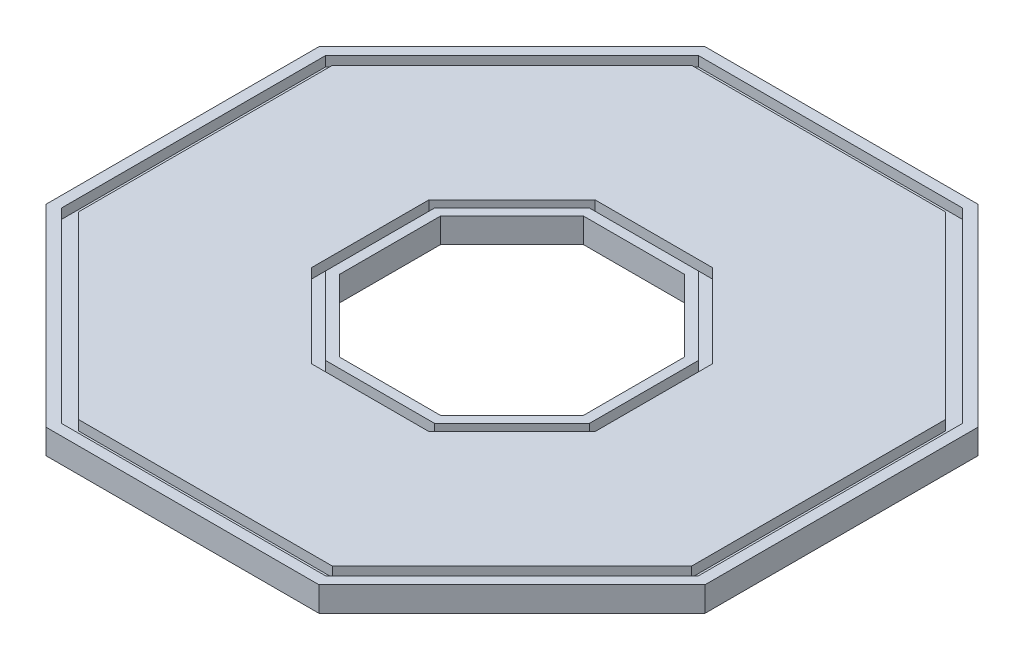
from build123d import *

# Parameters (mm, degrees)
EXTRUDE_1_DEPTH     = 2.5
CUT_EXTRUDE_1_DEPTH = 1
CUT_EXTRUDE_2_DEPTH = 3.8
CUT_EXTRUDE_3_DEPTH = 1


with BuildPart() as part:
    # 스케치1 → 보스-돌출1 (new body)
    with BuildSketch(Plane(origin=(0, 0, 0), x_dir=(1, 0, 0), z_dir=(0, 1, 0))):
        Polygon((-13.776603565, -33.25966317), (13.776603565, -33.25966317), (33.25966317, -13.776603565), (33.25966317, 13.776603565), (13.776603565, 33.25966317), (-13.776603565, 33.25966317), (-33.25966317, 13.776603565), (-33.25966317, -13.776603565), align=None)
    extrude(amount=EXTRUDE_1_DEPTH)

    # 스케치2 → 컷-돌출1 (cut)
    with BuildSketch(Plane(origin=(0, 2.5, 0), x_dir=(1, 0, 0), z_dir=(0, 1, 0))):
        Polygon((13.317383446, -32.151007731), (32.151007731, -13.317383446), (32.151007731, 13.317383446), (13.317383446, 32.151007731), (-13.317383446, 32.151007731), (-32.151007731, 13.317383446), (-32.151007731, -13.317383446), (-13.317383446, -32.151007731), align=None)
        Polygon((12.820327171, -30.951007731), (30.951007731, -12.820327171), (30.951007731, 12.820327171), (12.820327171, 30.951007731), (-12.820327171, 30.951007731), (-30.951007731, 12.820327171), (-30.951007731, -12.820327171), (-12.820327171, -30.951007731), align=None, mode=Mode.SUBTRACT)
    extrude(amount=-CUT_EXTRUDE_1_DEPTH, mode=Mode.SUBTRACT)

    # 스케치4 → 컷-돌출2 (cut)
    with BuildSketch(Plane(origin=(0, 2.5, 0), x_dir=(1, 0, 0), z_dir=(0, 1, 0))):
        Polygon((-5.103166077, -12.320132754), (5.103166077, -12.320132754), (12.320132754, -5.103166077), (12.320132754, 5.103166077), (5.103166077, 12.320132754), (-5.103166077, 12.320132754), (-12.320132754, 5.103166077), (-12.320132754, -5.103166077), align=None)
    extrude(amount=-CUT_EXTRUDE_2_DEPTH, mode=Mode.SUBTRACT)

    # 스케치4<3> → 컷-돌출3 (cut)
    with BuildSketch(Plane(origin=(0, 2.5, 0), x_dir=(1, 0, 0), z_dir=(0, 1, 0))):
        Polygon((-5.931593202, -14.320132754), (5.931593202, -14.320132754), (14.320132754, -5.931593202), (14.320132754, 5.931593202), (5.931593202, 14.320132754), (-5.931593202, 14.320132754), (-14.320132754, 5.931593202), (-14.320132754, -5.931593202), align=None)
        Polygon((13.320132754, -5.517379639), (5.517379639, -13.320132754), (-5.517379639, -13.320132754), (-13.320132754, -5.517379639), (-13.320132754, 5.517379639), (-5.517379639, 13.320132754), (5.517379639, 13.320132754), (13.320132754, 5.517379639), align=None, mode=Mode.SUBTRACT)
    extrude(amount=-CUT_EXTRUDE_3_DEPTH, mode=Mode.SUBTRACT)


solid = part.part
